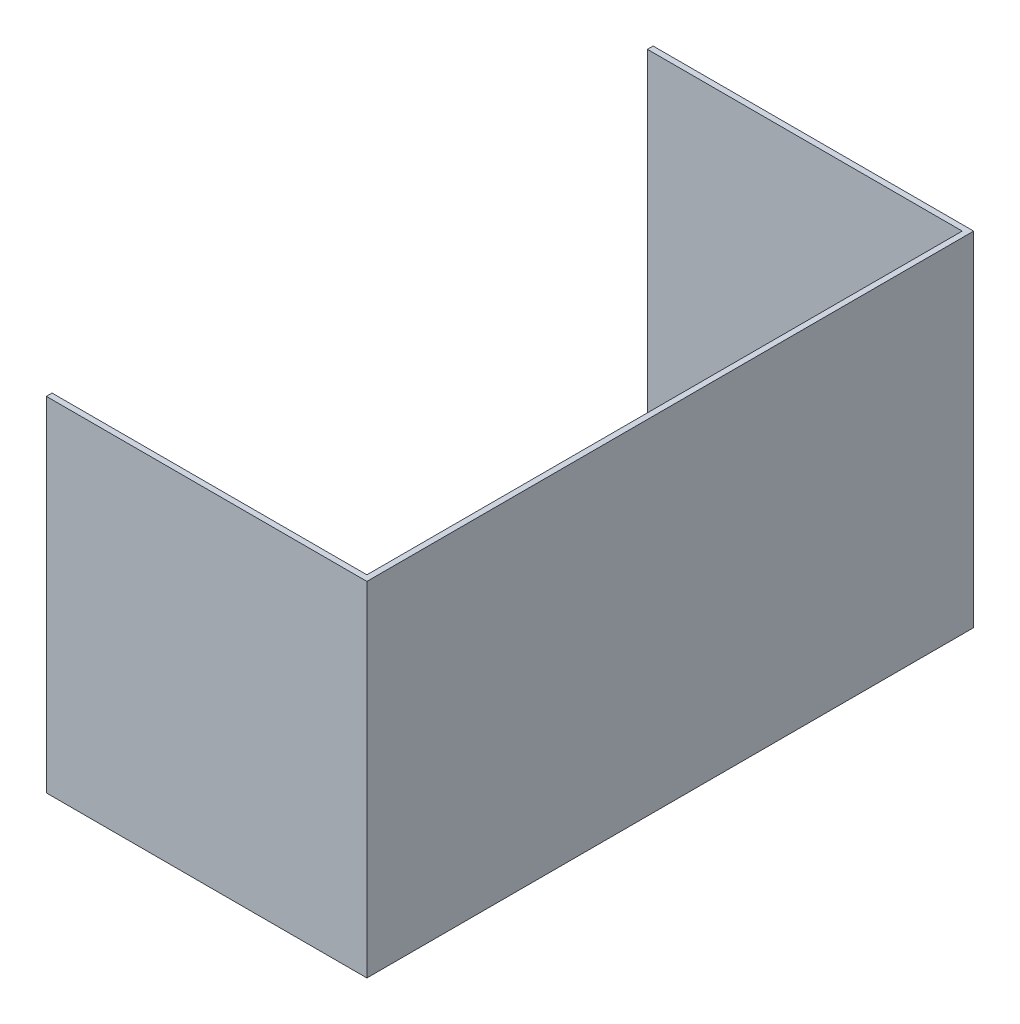
from build123d import *

# Parameters (mm, degrees)
BOSS_EXTRUDE1_DEPTH = 381


with BuildPart() as part:
    # Sketch1 → Boss-Extrude1 (new body)
    with BuildSketch(Plane(origin=(0, 0, 0), x_dir=(1, 0, 0), z_dir=(0, 1, 0))):
        Polygon((-6.35, 666.75), (-355.6, 666.75), (-355.6, 673.1), (0, 673.1), (0, 0), (-355.6, 0), (-355.6, 6.35), (-6.35, 6.35), align=None)
    extrude(amount=BOSS_EXTRUDE1_DEPTH)


solid = part.part
